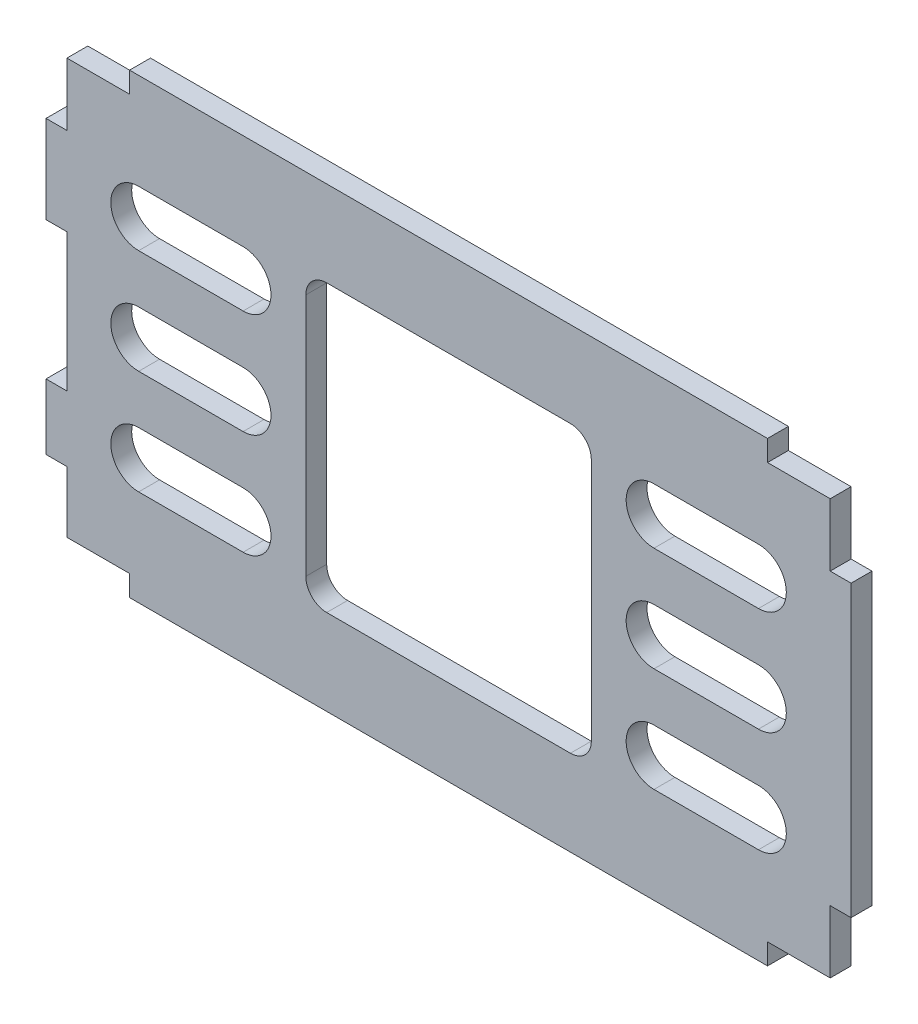
from build123d import *

# Parameters (mm, degrees)
EXTRUDE_2_DEPTH = 3


with BuildPart() as part:
    # 스케치5 → 보스-돌출2 (new body)
    with BuildSketch(Plane.XY.offset(70)):
        Polygon((54.8, -20.8), (57.8, -20.8), (57.8, 20.8), (54.8, 20.8), (54.8, 29.8), (45.8, 29.8), (45.8, 32.8), (-45.8, 32.8), (-45.8, 29.8), (-54.8, 29.8), (-54.8, 20.8), (-57.8, 20.8), (-57.8, 8.2), (-54.8, 8.2), (-54.8, -11.6), (-57.8, -11.6), (-57.8, -21), (-54.8, -21), (-54.8, -29.8), (-45.8, -29.8), (-45.8, -32.8), (45.8, -32.8), (45.8, -29.8), (54.8, -29.8), align=None)
        with BuildLine():
            Line((-17.5, 20.5), (17.5, 20.5))
            ThreePointArc((17.5, 20.5), (19.621320344, 19.621320344), (20.5, 17.5))
            Line((20.5, 17.5), (20.5, -17.5))
            ThreePointArc((20.5, -17.5), (19.621320344, -19.621320344), (17.5, -20.5))
            Line((17.5, -20.5), (-17.5, -20.5))
            ThreePointArc((-17.5, -20.5), (-19.621320344, -19.621320344), (-20.5, -17.5))
            Line((-20.5, -17.5), (-20.5, 17.5))
            ThreePointArc((-20.5, 17.5), (-19.621320344, 19.621320344), (-17.5, 20.5))
        make_face(mode=Mode.SUBTRACT)
        with BuildLine():
            Line((-29.5, 11), (-44.5, 11))
            ThreePointArc((-44.5, 11), (-48.5, 15), (-44.5, 19))
            Line((-44.5, 19), (-29.5, 19))
            ThreePointArc((-29.5, 19), (-25.5, 15), (-29.5, 11))
        make_face(mode=Mode.SUBTRACT)
        with BuildLine():
            Line((29.5, -11), (44.5, -11))
            ThreePointArc((44.5, -11), (48.5, -15), (44.5, -19))
            Line((44.5, -19), (29.5, -19))
            ThreePointArc((29.5, -19), (25.5, -15), (29.5, -11))
        make_face(mode=Mode.SUBTRACT)
        with BuildLine():
            Line((29.5, 4), (44.5, 4))
            ThreePointArc((44.5, 4), (48.5, 0), (44.5, -4))
            Line((44.5, -4), (29.5, -4))
            ThreePointArc((29.5, -4), (25.5, 0), (29.5, 4))
        make_face(mode=Mode.SUBTRACT)
        with BuildLine():
            Line((29.5, 19), (44.5, 19))
            ThreePointArc((44.5, 19), (48.5, 15), (44.5, 11))
            Line((44.5, 11), (29.5, 11))
            ThreePointArc((29.5, 11), (25.5, 15), (29.5, 19))
        make_face(mode=Mode.SUBTRACT)
        with BuildLine():
            Line((-29.5, -19), (-44.5, -19))
            ThreePointArc((-44.5, -19), (-48.5, -15), (-44.5, -11))
            Line((-44.5, -11), (-29.5, -11))
            ThreePointArc((-29.5, -11), (-25.5, -15), (-29.5, -19))
        make_face(mode=Mode.SUBTRACT)
        with BuildLine():
            Line((-29.5, -4), (-44.5, -4))
            ThreePointArc((-44.5, -4), (-48.5, 0), (-44.5, 4))
            Line((-44.5, 4), (-29.5, 4))
            ThreePointArc((-29.5, 4), (-25.5, 0), (-29.5, -4))
        make_face(mode=Mode.SUBTRACT)
    extrude(amount=-EXTRUDE_2_DEPTH)


solid = part.part
